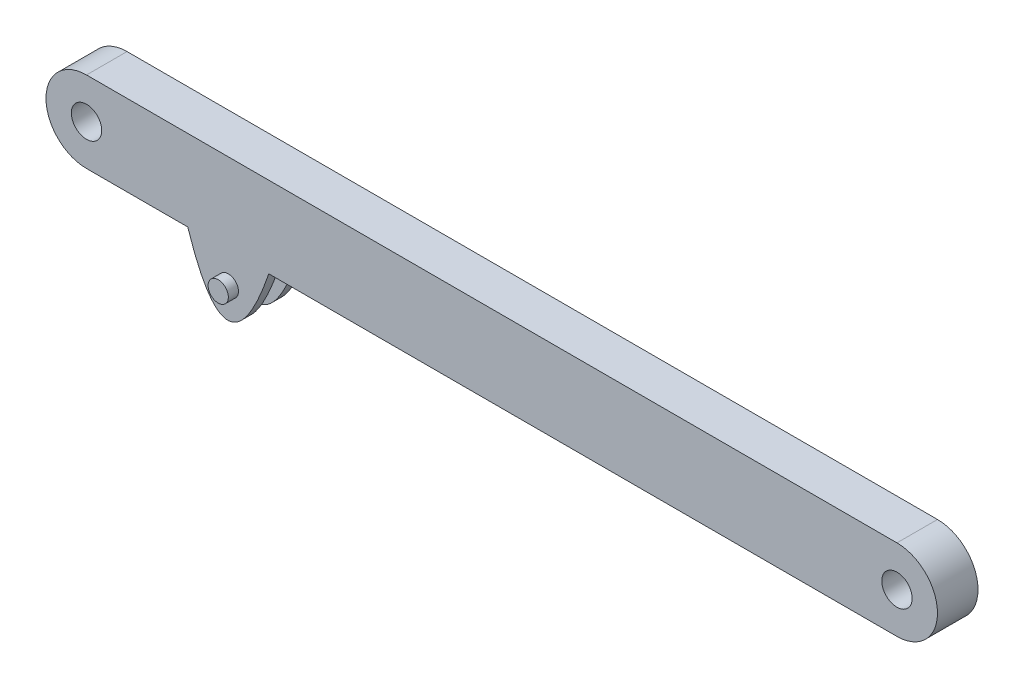
from build123d import *

# Parameters (mm, degrees)
BOSS_EXTRUDE1_DEPTH = 20
SKETCH4_R           = 7.5
CUT_EXTRUDE1_DEPTH  = 20
BOSS_EXTRUDE2_DEPTH = 5
BOSS_EXTRUDE3_START = -5
SKETCH9_R           = 5
BOSS_EXTRUDE3_DEPTH = 15


with BuildPart() as part:
    # Sketch2 → Boss-Extrude1 (new body)
    with BuildSketch(Plane.XY):
        with BuildLine():
            Line((-200, 20), (200, 20))
            ThreePointArc((200, 20), (220, 0), (200, -20))
            Line((200, -20), (-200, -20))
            ThreePointArc((-200, -20), (-220, 0), (-200, 20))
        make_face()
    extrude(amount=BOSS_EXTRUDE1_DEPTH)

    # Sketch4 → Cut-Extrude1 (cut)
    with BuildSketch(Plane.XY.offset(20)):
        with Locations((-200, 0)):
            Circle(SKETCH4_R)
        with Locations((200, 0)):
            Circle(SKETCH4_R)
    extrude(amount=-CUT_EXTRUDE1_DEPTH, mode=Mode.SUBTRACT)

    # Sketch8 → Boss-Extrude2 (add)
    with BuildSketch(Plane.XY):
        with BuildLine():
            Line((-150.037555006, -20), (-110.037555006, -20))
            add(Edge.make_bspline(
                [(-150.037555006, -20), (-130.493208153, -80.001537629), (-110.037555006, -20)],
                knots=[0, 0, 0, 1, 1, 1], degree=2))
        make_face()
    boss_extrude2 = extrude(amount=BOSS_EXTRUDE2_DEPTH)

    # Sketch9 → Boss-Extrude3 (add)
    with BuildSketch(Plane.XY.offset(BOSS_EXTRUDE3_START)):
        with Locations((-130, -35)):
            Circle(SKETCH9_R)
    boss_extrude3 = extrude(amount=BOSS_EXTRUDE3_DEPTH)

    # Mirror2: Boss-Extrude2, Boss-Extrude3 across plane
    add(boss_extrude2.mirror(Plane.XY.offset(10)))
    add(boss_extrude3.mirror(Plane.XY.offset(10)))


solid = part.part
